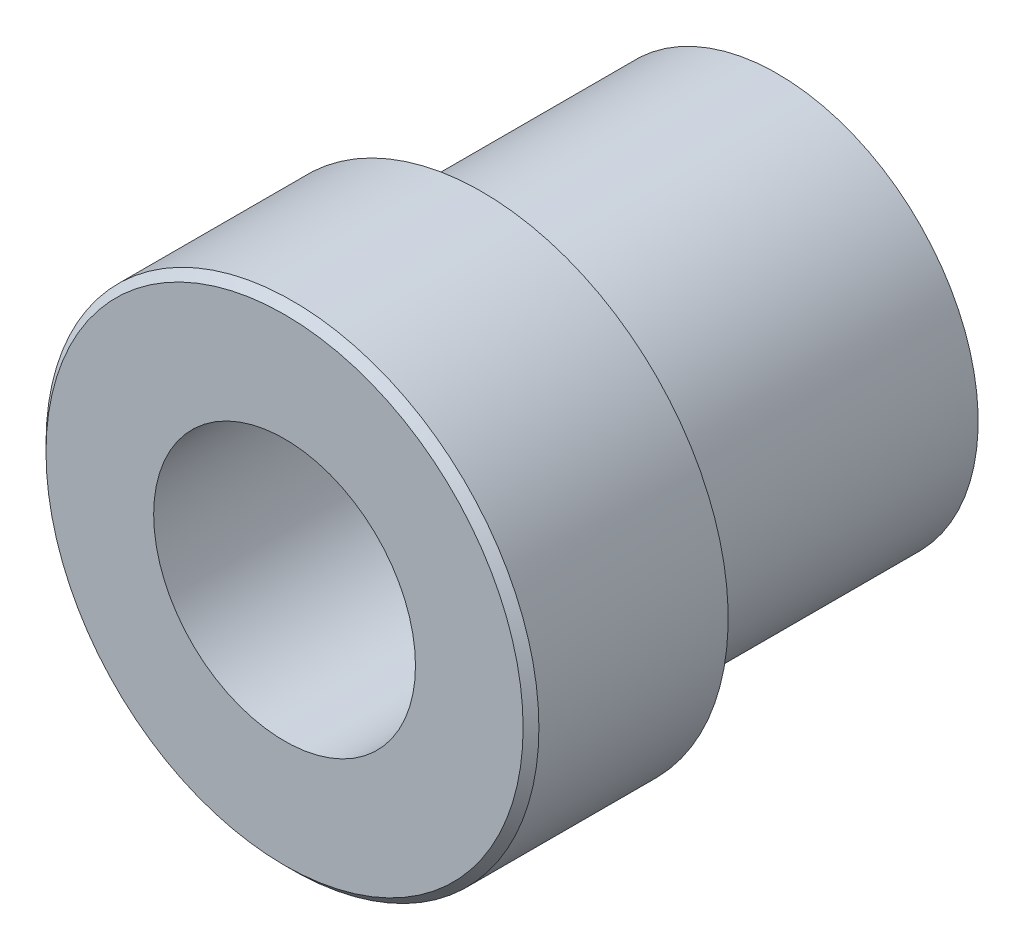
from build123d import *

# Parameters (mm, degrees)
SKETCH1_R                   = 7.9375
BOSS_EXTRUDE1_DEPTH         = 15.875
CHAMFER1_SIZE               = 0.254
SKETCH2_OUTSIDE_W           = 23.376
SKETCH2_OUTSIDE_H           = 23.376
SKETCH2_OUTSIDE_R           = 6.4643
CUT_EXTRUDE1_DEPTH          = 9.525
TAP_DRILL_FOR_3_8_24_TAP1_D = 8.4328


with BuildPart() as part:
    # Sketch1 → Boss-Extrude1 (new body)
    with BuildSketch(Plane.XY):
        Circle(SKETCH1_R)
    extrude(amount=BOSS_EXTRUDE1_DEPTH)

    # Chamfer1
    chamfer1_edges = [part.edges().sort_by_distance(p)[0] for p in [
        (-7.9375, 0, 15.875),
    ]]
    chamfer(chamfer1_edges, length=CHAMFER1_SIZE)

    # Sketch2 outside → Cut-Extrude1 (cut)
    with BuildSketch(Plane(origin=(0, 0, 0), x_dir=(-1, 0, 0), z_dir=(0, 0, -1))):
        Rectangle(SKETCH2_OUTSIDE_W, SKETCH2_OUTSIDE_H)
        Circle(SKETCH2_OUTSIDE_R, mode=Mode.SUBTRACT)
    extrude(amount=-CUT_EXTRUDE1_DEPTH, mode=Mode.SUBTRACT)

    # Tap Drill for 3/8-24 Tap1 (through all)
    with Locations(Plane.XY.offset(15.875)):
        with Locations((0, 0)):
            Hole(TAP_DRILL_FOR_3_8_24_TAP1_D / 2)


solid = part.part
